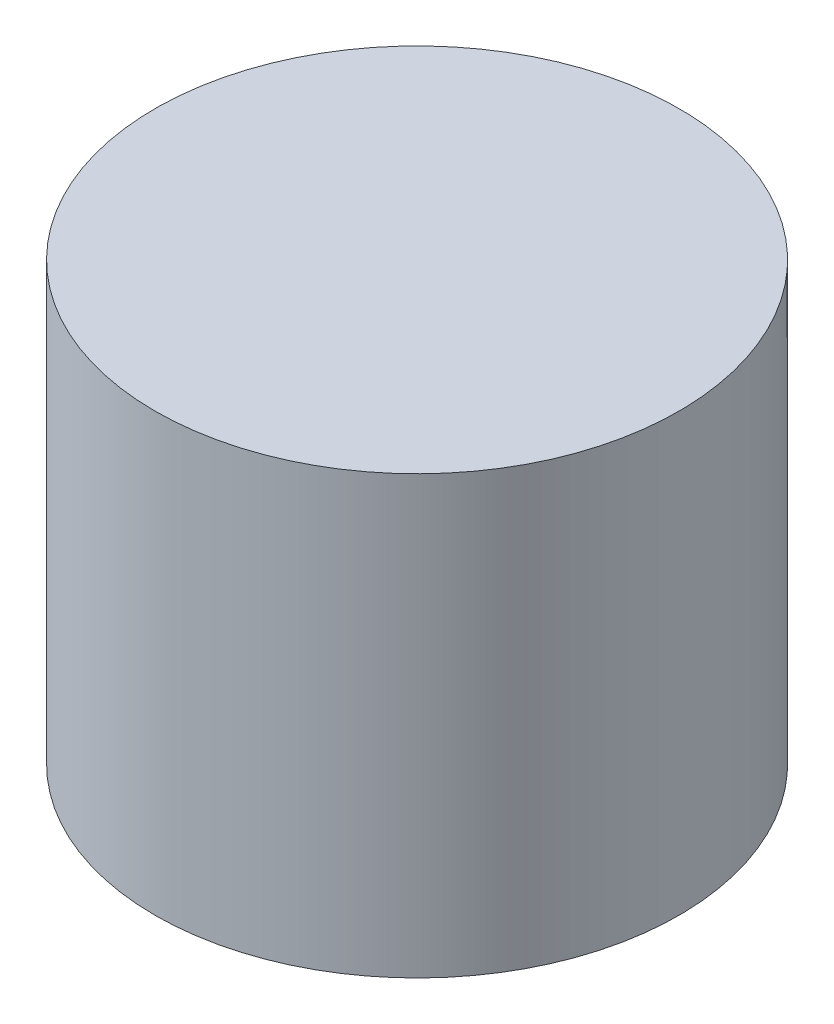
from build123d import *


with BuildPart() as part:
    # Esquisse1 → Révolution1 (revolve)
    with BuildSketch(Plane.XY):
        Polygon((0, 0), (12.5, 0), (12.5, -0.1), (15, -0.1), (15, 24.9), (0, 24.9), align=None)
    revolve(axis=Axis((0, 24.9, 0), (0, -1, 0)))


solid = part.part
